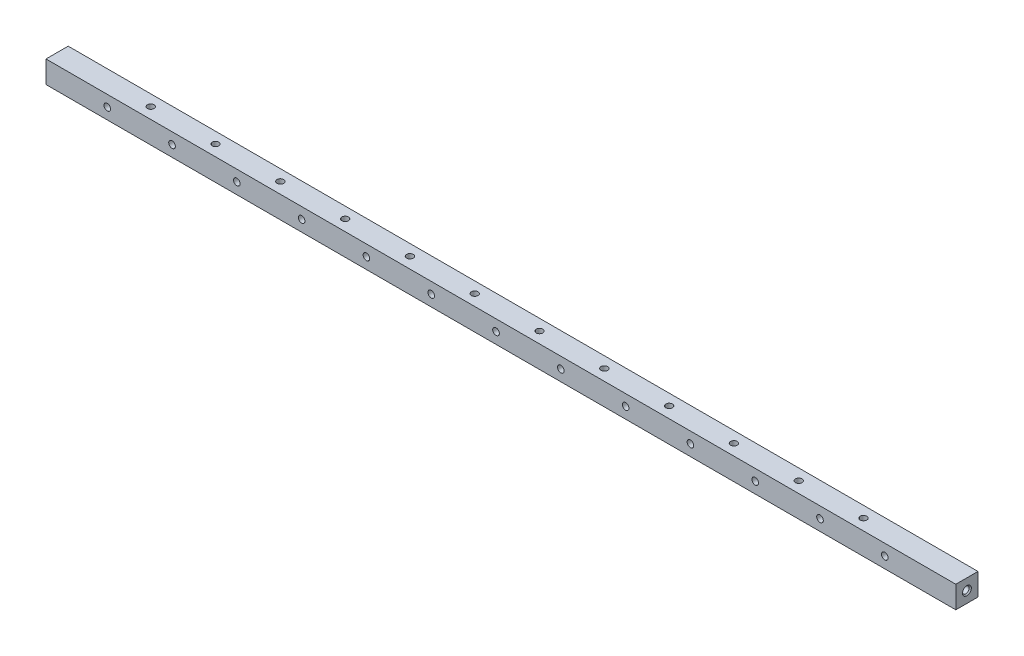
from build123d import *

# Parameters (mm, degrees)
SKETCH1_W                        = 12.7
SKETCH1_H                        = 12.7
BOSS_EXTRUDE1_DEPTH              = 520.7
F_10_24_TAPPED_HOLE1_D           = 3.7973
F_10_24_TAPPED_HOLE2_D           = 3.7973
M6X1_0_TAPPED_HOLE2_D            = 5
M6X1_0_TAPPED_HOLE2_DEPTH        = 20.32
M6X1_0_TAPPED_HOLE2_CSINK_D      = 6.05
M6X1_0_TAPPED_HOLE2_CSINK_ANGLE  = 90
M6X1_0_TAPPED_HOLE2_TIP          = 1.502151548
F_10_24_TAPPED_HOLE3_D           = 3.7973
F_10_24_TAPPED_HOLE3_DEPTH       = 20.574
F_10_24_TAPPED_HOLE3_CSINK_D     = 5.0673
F_10_24_TAPPED_HOLE3_CSINK_ANGLE = 90
F_10_24_TAPPED_HOLE3_TIP         = 1.140824014
LPATTERN1_COUNT                  = 13
LPATTERN1_PITCH                  = 37.084
LPATTERN2_COUNT                  = 12
LPATTERN2_PITCH                  = 37.084


with BuildPart() as part:
    # Sketch1 → Boss-Extrude1 (new body)
    with BuildSketch(Plane(origin=(0, 0, 0), x_dir=(0, 0, -1), z_dir=(1, 0, 0))):
        Rectangle(SKETCH1_W, SKETCH1_H)
    extrude(amount=BOSS_EXTRUDE1_DEPTH)

    # #10-24 Tapped Hole1 (through all)
    with Locations(Plane.XY.offset(6.35)):
        with Locations((35.052, 0)):
            f_10_24_tapped_hole1 = Hole(F_10_24_TAPPED_HOLE1_D / 2)

    # #10-24 Tapped Hole2 (through all)
    with Locations(Plane(origin=(0, 6.35, 0), x_dir=(1, 0, 0), z_dir=(0, 1, 0))):
        with Locations((53.594, 0)):
            f_10_24_tapped_hole2 = Hole(F_10_24_TAPPED_HOLE2_D / 2)

    # M6x1.0 Tapped Hole2
    with Locations(Plane.ZY):
        with Locations((0, 0)):
            CounterSinkHole(M6X1_0_TAPPED_HOLE2_D / 2, M6X1_0_TAPPED_HOLE2_CSINK_D / 2, depth=M6X1_0_TAPPED_HOLE2_DEPTH, counter_sink_angle=M6X1_0_TAPPED_HOLE2_CSINK_ANGLE)
            with Locations((0, 0, -(M6X1_0_TAPPED_HOLE2_DEPTH + M6X1_0_TAPPED_HOLE2_TIP / 2))):  # 118° drill point
                Cone(0, M6X1_0_TAPPED_HOLE2_D / 2, M6X1_0_TAPPED_HOLE2_TIP, mode=Mode.SUBTRACT)

    # #10-24 Tapped Hole3
    with Locations(Plane(origin=(520.7, 0, 0), x_dir=(0, 0, -1), z_dir=(1, 0, 0))):
        with Locations((0, 0)):
            CounterSinkHole(F_10_24_TAPPED_HOLE3_D / 2, F_10_24_TAPPED_HOLE3_CSINK_D / 2, depth=F_10_24_TAPPED_HOLE3_DEPTH, counter_sink_angle=F_10_24_TAPPED_HOLE3_CSINK_ANGLE)
            with Locations((0, 0, -(F_10_24_TAPPED_HOLE3_DEPTH + F_10_24_TAPPED_HOLE3_TIP / 2))):  # 118° drill point
                Cone(0, F_10_24_TAPPED_HOLE3_D / 2, F_10_24_TAPPED_HOLE3_TIP, mode=Mode.SUBTRACT)

    # LPattern1: #10-24 Tapped Hole1 ×13
    with Locations(*[(i * LPATTERN1_PITCH, 0, 0) for i in range(1, LPATTERN1_COUNT)]):
        add(f_10_24_tapped_hole1, mode=Mode.SUBTRACT)

    # LPattern2: #10-24 Tapped Hole2 ×12
    with Locations(*[(i * LPATTERN2_PITCH, 0, 0) for i in range(1, LPATTERN2_COUNT)]):
        add(f_10_24_tapped_hole2, mode=Mode.SUBTRACT)


solid = part.part
